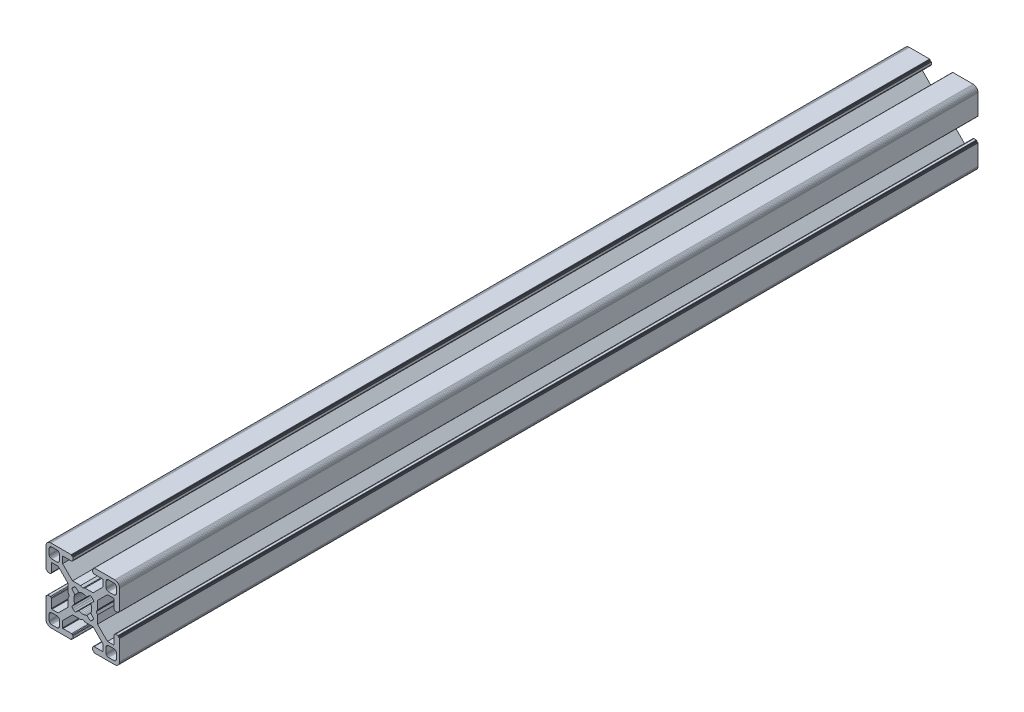
from build123d import *

# Parameters (mm, degrees)
BOSS_EXTRUDE1_DEPTH = 350


with BuildPart() as part:
    # Sketch1 → Boss-Extrude1 (new body)
    with BuildSketch(Plane.XY):
        Polygon((28.34729664, 29.969613999), (28.000000864, 29.999999329), (19.750000909, 29.999999329), (19.715268165, 29.996961355), (19.681595266, 29.987938702), (19.649999216, 29.973205179), (19.621443003, 29.953207821), (19.596790895, 29.928557575), (19.576793537, 29.899999499), (19.562061876, 29.868405312), (19.55303736, 29.834728688), (19.549999386, 29.799999669), (19.549999386, 29.699999839), (19.546961412, 29.665268958), (19.537936896, 29.631596059), (19.523203373, 29.599998146), (19.503207877, 29.571441934), (19.478557631, 29.546789825), (19.449999556, 29.526794329), (19.418403506, 29.512060806), (19.384728745, 29.503038153), (19.349999726, 29.500000179), (19.249999896, 29.500000179), (19.215267517, 29.496958527), (19.181592755, 29.487935874), (19.149996706, 29.47320235), (19.12143863, 29.453206855), (19.096788384, 29.428554746), (19.076791026, 29.399996671), (19.062057503, 29.368402484), (19.05303485, 29.334725859), (19.049996876, 29.299998703), (19.049996876, 28.39999837), (19.059110798, 28.29580945), (19.08618062, 28.194785165), (19.13038119, 28.099997016), (19.190369539, 28.014324653), (19.264324002, 27.94037019), (19.349996366, 27.88038184), (19.444784515, 27.836181271), (19.545806937, 27.809111449), (19.650010894, 27.799984574), (23.050010706, 27.799984574), (23.084741588, 27.7969466), (23.118414487, 27.787923946), (23.150012399, 27.773190423), (23.178568612, 27.753193065), (23.203220721, 27.728542819), (23.223218079, 27.699984744), (23.237949739, 27.668386831), (23.246974255, 27.634713932), (23.25001142, 27.59998608), (23.25001142, 25.049987618), (19.204474482, 20.999982084), (15.900007876, 20.999982084), (15.000008474, 20.48483404), (14.10000814, 20.999982084), (10.795543398, 20.999982084), (7.997342887, 23.801274731), (6.750011387, 25.049984589), (6.750011387, 27.599983051), (6.753049362, 27.634713932), (6.762072946, 27.668386831), (6.776805538, 27.699984744), (6.796801965, 27.728542819), (6.821454073, 27.753193065), (6.850011218, 27.773190423), (6.881607267, 27.787923946), (6.915282029, 27.7969466), (6.950011048, 27.799984574), (10.350011791, 27.799984574), (10.45420071, 27.809098497), (10.555223133, 27.836168318), (10.650011282, 27.880368888), (10.735683645, 27.940357238), (10.809638108, 28.014311701), (10.869626458, 28.099984064), (10.913827027, 28.194772213), (10.940895918, 28.295796498), (10.950010772, 28.399985417), (10.950010772, 29.299985751), (10.946974575, 29.334739239), (10.93795065, 29.368415522), (10.923215933, 29.400009153), (10.903218427, 29.428566473), (10.878566319, 29.45321765), (10.849999264, 29.473204166), (10.818403214, 29.487937689), (10.784728453, 29.496960342), (10.749999434, 29.500000179), (10.649999604, 29.500000179), (10.615270585, 29.503038153), (10.581595823, 29.512060806), (10.549999774, 29.526794329), (10.521441698, 29.546789825), (10.496791452, 29.571441934), (10.476795025, 29.599998146), (10.462061502, 29.631596059), (10.453037918, 29.665268958), (10.449999943, 29.699999839), (10.449999943, 29.799999669), (10.446961969, 29.834728688), (10.437938385, 29.868405312), (10.423205793, 29.899999499), (10.403208435, 29.928557575), (10.378557257, 29.953207821), (10.350000113, 29.973205179), (10.318404064, 29.987938702), (10.284729302, 29.996961355), (10.250000283, 29.999999329), (1.999999397, 29.999999329), (1.652702689, 29.969613999), (1.315958682, 29.879383743), (0.999999233, 29.732050374), (0.714424066, 29.532089829), (0.467910431, 29.285576195), (0.267948955, 28.999999166), (0.120614655, 28.684040532), (0.030384399, 28.34729664), (0, 28.000000864), (0, 19.750000909), (0.003037974, 19.715268165), (0.012061559, 19.681595266), (0.026795082, 19.649999216), (0.046790577, 19.621441141), (0.071442686, 19.596789032), (0.09999983, 19.576793537), (0.13159588, 19.562060013), (0.165270641, 19.55303736), (0.19999966, 19.549999386), (0.299999461, 19.549999386), (0.334728509, 19.546959549), (0.368403242, 19.537936896), (0.399999321, 19.523203373), (0.428556465, 19.503207877), (0.453208573, 19.478555769), (0.473204069, 19.449997693), (0.487937592, 19.418403506), (0.496961176, 19.384728745), (0.499999151, 19.349999726), (0.499999151, 19.249998033), (0.503038056, 19.215269014), (0.512060709, 19.181594253), (0.526794232, 19.150000066), (0.546790194, 19.121441524), (0.571441837, 19.096789882), (0.60000029, 19.076794925), (0.631595686, 19.062061999), (0.665270619, 19.053039982), (0.700000626, 19.050000801), (1.60000096, 19.050000801), (1.704189879, 19.059116587), (1.805213233, 19.086186409), (1.90000045, 19.130385115), (1.985673745, 19.190375328), (2.059627277, 19.264327928), (2.119616325, 19.350002154), (2.163816196, 19.444788441), (2.190886018, 19.545812726), (2.200000872, 19.650001645), (2.200000872, 23.050001457), (2.203039777, 23.084732338), (2.212062431, 23.118405237), (2.226795954, 23.15000315), (2.246792381, 23.178559362), (2.271443558, 23.203211471), (2.300000702, 23.223206967), (2.331596752, 23.23794049), (2.365271513, 23.246965006), (2.400001464, 23.250001117), (4.950000857, 23.250001117), (7.997332093, 20.202670812), (8.995535423, 19.204467788), (8.995535423, 15.900001182), (9.515148227, 15.00000178), (8.995535423, 14.100002378), (8.995535423, 10.795536704), (4.950000857, 6.750002138), (2.400001464, 6.750002138), (2.365271513, 6.753040112), (2.331596752, 6.762063697), (2.300000702, 6.77679722), (2.271443558, 6.796793647), (2.246792381, 6.821444824), (2.226795954, 6.850001968), (2.212062431, 6.881598018), (2.203039777, 6.915272779), (2.200000872, 6.950002729), (2.200000872, 10.350002542), (2.190896812, 10.454174265), (2.16382699, 10.555197618), (2.119627119, 10.649984836), (2.059638071, 10.735658131), (1.985684539, 10.809611663), (1.900011244, 10.869600944), (1.805224027, 10.913800582), (1.704200673, 10.940870404), (1.600011754, 10.949986189), (0.70001142, 10.949986189), (0.665281355, 10.946948596), (0.631606253, 10.937926283), (0.600010578, 10.923193954), (0.571451747, 10.903199537), (0.546799638, 10.87854836), (0.526794232, 10.850000195), (0.512060709, 10.818404146), (0.503038056, 10.784730315), (0.499999151, 10.750000365), (0.499999151, 10.650000535), (0.496961176, 10.615270585), (0.487937592, 10.581596754), (0.473204069, 10.550000705), (0.453208573, 10.521443561), (0.428556465, 10.496791452), (0.399999321, 10.476795956), (0.368403242, 10.462062433), (0.334728509, 10.453038849), (0.299999461, 10.449999943), (0.19999966, 10.449999943), (0.165270641, 10.446961969), (0.13159588, 10.437939316), (0.09999983, 10.423205793), (0.071442686, 10.403209366), (0.046790577, 10.378558189), (0.026795082, 10.350000113), (0.012061559, 10.318404064), (0.003037974, 10.284729302), (0, 10.250000283), (0, 1.999999397), (0.030384399, 1.652702689), (0.120614655, 1.315958682), (0.267948955, 0.999999233), (0.467910431, 0.714424066), (0.714424066, 0.467910431), (0.999999233, 0.267948955), (1.315958682, 0.120614655), (1.652702689, 0.030384399), (1.999999397, 0), (10.250000283, 0), (10.284729302, 0.003037974), (10.318404064, 0.012061559), (10.350000113, 0.026795082), (10.378557257, 0.046790577), (10.403208435, 0.071442686), (10.423205793, 0.09999983), (10.437938385, 0.13159588), (10.446961969, 0.165270641), (10.449999943, 0.19999966), (10.449999943, 0.300000422), (10.453037918, 0.334729441), (10.462061502, 0.368404202), (10.476795025, 0.400000252), (10.496791452, 0.428557396), (10.521441698, 0.453208573), (10.549999774, 0.473205), (10.581595823, 0.487938523), (10.615270585, 0.496961176), (10.649999604, 0.500000082), (10.749999434, 0.500000082), (10.784728453, 0.503038056), (10.818403214, 0.512060709), (10.849999264, 0.526794232), (10.878547894, 0.546800104), (10.903198606, 0.571451747), (10.923194493, 0.6000102), (10.93792742, 0.631606528), (10.946949437, 0.66528146), (10.950010772, 0.699984975), (10.950010772, 1.599985308), (10.940895918, 1.704174228), (10.913827027, 1.805197581), (10.869626458, 1.89998573), (10.809638108, 1.985658094), (10.735683645, 2.059612557), (10.650011282, 2.119600674), (10.555223133, 2.163801476), (10.45420071, 2.190870367), (10.350011791, 2.199985221), (6.950011048, 2.199985221), (6.915282029, 2.203024126), (6.881607267, 2.212046779), (6.850011218, 2.226780302), (6.821454073, 2.246776729), (6.796801965, 2.271427907), (6.776805538, 2.299985982), (6.762072946, 2.331582032), (6.753049362, 2.365256793), (6.750011387, 2.399985812), (6.750011387, 4.949985206), (9.787457566, 7.990785077), (10.795545277, 8.999985833), (14.100010019, 8.999985833), (15.000010353, 9.515133877), (15.900009756, 8.999985833), (19.204476361, 8.999985833), (20.21256413, 7.990786065), (23.25001142, 4.949988235), (23.25001142, 2.399988841), (23.246974255, 2.365256793), (23.237949739, 2.331582032), (23.223218079, 2.299985982), (23.203220721, 2.271427907), (23.178568612, 2.246776729), (23.150012399, 2.226780302), (23.118414487, 2.212046779), (23.084741588, 2.203024126), (23.050010706, 2.199985221), (19.650010894, 2.199985221), (19.545806937, 2.190883319), (19.444784515, 2.163814428), (19.349996366, 2.119613626), (19.264324002, 2.059625509), (19.190369539, 1.985671046), (19.13038119, 1.899998682), (19.08618062, 1.805210533), (19.059110798, 1.70418718), (19.049996876, 1.599998261), (19.049996876, 0.699997927), (19.053035506, 0.665268966), (19.062058795, 0.631594374), (19.076792915, 0.599998603), (19.096790813, 0.571440905), (19.121441524, 0.546790194), (19.149999978, 0.526794306), (19.181596306, 0.51206138), (19.215271238, 0.503039363), (19.249999896, 0.500000082), (19.349999726, 0.500000082), (19.384728745, 0.496961176), (19.418403506, 0.487938523), (19.449999556, 0.473205), (19.478557631, 0.453208573), (19.503207877, 0.428557396), (19.523203373, 0.400000252), (19.537936896, 0.368404202), (19.546961412, 0.334729441), (19.549999386, 0.300000422), (19.549999386, 0.19999966), (19.55303736, 0.165270641), (19.562061876, 0.13159588), (19.576793537, 0.09999983), (19.596789964, 0.071441755), (19.621442072, 0.046789646), (19.649998285, 0.02679415), (19.681594335, 0.012060627), (19.715267234, 0.003037043), (19.750000909, 0), (28.000000864, 0), (28.34729664, 0.030384399), (28.684040532, 0.120614655), (28.999999166, 0.267948955), (29.285576195, 0.467910431), (29.532089829, 0.714424066), (29.732050374, 0.999999233), (29.879383743, 1.315958682), (29.969613999, 1.652702689), (29.999999329, 1.999999397), (29.999999329, 10.250000283), (29.996974806, 10.284715361), (29.987951516, 10.318389952), (29.973217396, 10.349985723), (29.953219499, 10.378543421), (29.928568787, 10.403194133), (29.899999499, 10.423205793), (29.868405312, 10.437939316), (29.834728688, 10.446961969), (29.799999669, 10.449999943), (29.699999839, 10.449999943), (29.664909937, 10.453400043), (29.631233313, 10.462423628), (29.599637263, 10.477157151), (29.57108105, 10.497152646), (29.546427079, 10.521804755), (29.526433446, 10.550361899), (29.511699923, 10.581957949), (29.502675407, 10.615631779), (29.499637433, 10.650361729), (29.499637433, 10.750361559), (29.49697202, 10.784715548), (29.487949367, 10.818389378), (29.473215844, 10.849985428), (29.453220348, 10.878542572), (29.428568239, 10.90319468), (29.400010164, 10.923190176), (29.368415977, 10.937923699), (29.334741215, 10.946947284), (29.300012197, 10.949986189), (28.400011863, 10.949986189), (28.29581215, 10.9408876), (28.194787865, 10.913817778), (28.099999716, 10.86961814), (28.014327352, 10.809628859), (27.940374752, 10.735675327), (27.880384539, 10.650002032), (27.836185833, 10.555214814), (27.809114148, 10.454191461), (27.800000225, 10.350002542), (27.800000225, 6.950002729), (27.796962251, 6.915272779), (27.787939598, 6.881598018), (27.773206075, 6.850001968), (27.753208716, 6.821444824), (27.728558471, 6.796793647), (27.700000395, 6.77679722), (27.668404345, 6.762063697), (27.634729584, 6.753040112), (27.599998702, 6.750002138), (25.05000024, 6.750002138), (23.809199132, 7.99080223), (21.004464477, 10.795534588), (21.004464477, 14.100000262), (20.484851673, 14.999999665), (21.004464477, 15.899999067), (21.004464477, 19.204465672), (25.05000024, 23.250001117), (27.599998702, 23.250001117), (27.634729584, 23.246965006), (27.668404345, 23.23794049), (27.700000395, 23.223206967), (27.728558471, 23.203211471), (27.753208716, 23.178559362), (27.773206075, 23.15000315), (27.787939598, 23.118405237), (27.796962251, 23.084732338), (27.800000225, 23.050001457), (27.800000225, 19.650001645), (27.809114148, 19.545812726), (27.836185833, 19.444788441), (27.880384539, 19.350002154), (27.940370508, 19.264323684), (28.014323108, 19.190371084), (28.099995472, 19.130380872), (28.194783621, 19.086182165), (28.295807906, 19.059112343), (28.400001069, 19.050000801), (29.300001402, 19.050000801), (29.334730421, 19.053040638), (29.368405183, 19.062063291), (29.39999937, 19.076796814), (29.42819671, 19.097149726), (29.452848353, 19.1218023), (29.472843309, 19.150360754), (29.487576235, 19.181955219), (29.496598252, 19.215630151), (29.499637433, 19.250359227), (29.499637433, 19.35036092), (29.502675407, 19.385089939), (29.511699923, 19.4187647), (29.526433446, 19.450358887), (29.546427079, 19.478916963), (29.57108105, 19.503569071), (29.599637263, 19.523564567), (29.631233313, 19.53829809), (29.664909937, 19.547320743), (29.699999839, 19.549999386), (29.799999669, 19.549999386), (29.834728688, 19.55303736), (29.868405312, 19.562060013), (29.899999499, 19.576793537), (29.928557575, 19.596789032), (29.953207821, 19.621441141), (29.973205179, 19.649999216), (29.987938702, 19.681595266), (29.996961355, 19.715268165), (29.999999329, 19.750000909), (29.999999329, 28.000000864), (29.969613999, 28.34729664), (29.879383743, 28.684040532), (29.732050374, 28.999999166), (29.532089829, 29.285576195), (29.285576195, 29.532089829), (28.999999166, 29.732050374), (28.684040532, 29.879383743), align=None)
        Polygon((1.299998723, 25.499999523), (1.299998723, 27.699999511), (1.312309876, 27.856435627), (1.348942518, 28.009016067), (1.408992335, 28.153989464), (1.490981318, 28.287785128), (1.592892222, 28.407108039), (1.71221327, 28.50901708), (1.846008119, 28.591006994), (1.9909814, 28.651056811), (2.143563703, 28.687689453), (2.299998887, 28.699999675), (4.499998875, 28.699999675), (4.656434059, 28.687689453), (4.809016362, 28.651056811), (4.953989759, 28.591006994), (5.087784491, 28.50901708), (5.207106471, 28.407108039), (5.309016444, 28.287785128), (5.391005427, 28.153989464), (5.451056175, 28.009016067), (5.487687886, 27.856435627), (5.499999039, 27.699999511), (5.499999039, 25.499999523), (5.487687886, 25.34356527), (5.451056175, 25.190982968), (5.391005427, 25.04600957), (5.309016444, 24.912213907), (5.207106471, 24.792892858), (5.087784491, 24.690981954), (4.953989759, 24.60899204), (4.809016362, 24.548944086), (4.656434059, 24.512309581), (4.499998875, 24.499999359), (2.299998887, 24.499999359), (2.143563703, 24.512309581), (1.9909814, 24.548944086), (1.846008119, 24.60899204), (1.71221327, 24.690981954), (1.592892222, 24.792892858), (1.490981318, 24.912213907), (1.408992335, 25.04600957), (1.348942518, 25.190982968), (1.312309876, 25.34356527), align=None, mode=Mode.SUBTRACT)
        Polygon((25.34356527, 28.687689453), (25.499999523, 28.699999675), (27.699999511, 28.699999675), (27.856435627, 28.687689453), (28.009017929, 28.651056811), (28.153991327, 28.591006994), (28.28778699, 28.50901708), (28.407108039, 28.407108039), (28.50901708, 28.287785128), (28.591006994, 28.153989464), (28.651056811, 28.009016067), (28.687689453, 27.856435627), (28.700001538, 27.699999511), (28.700001538, 25.499999523), (28.687689453, 25.34356527), (28.651056811, 25.190982968), (28.591006994, 25.04600957), (28.50901708, 24.912213907), (28.407108039, 24.792892858), (28.28778699, 24.690981954), (28.153991327, 24.60899204), (28.009017929, 24.548944086), (27.856435627, 24.512309581), (27.699999511, 24.499999359), (25.499999523, 24.499999359), (25.34356527, 24.512309581), (25.190982968, 24.548944086), (25.04600957, 24.60899204), (24.912215769, 24.690981954), (24.792892858, 24.792892858), (24.690981954, 24.912213907), (24.608993903, 25.04600957), (24.548944086, 25.190982968), (24.512311444, 25.34356527), (24.500001222, 25.499999523), (24.500001222, 27.699999511), (24.512311444, 27.856435627), (24.548944086, 28.009016067), (24.608993903, 28.153989464), (24.690981954, 28.287785128), (24.792892858, 28.407108039), (24.912215769, 28.50901708), (25.04600957, 28.591006994), (25.190982968, 28.651056811), align=None, mode=Mode.SUBTRACT)
        Polygon((14.999999665, 18.649999052), (15.550030395, 18.608318642), (16.087498516, 18.484227359), (16.600128263, 18.280562013), (18.13592948, 19.518401474), (18.644984812, 19.11874488), (19.103571773, 18.662061542), (19.505336881, 18.154669553), (18.280562013, 16.600130126), (18.484227359, 16.087498516), (18.608318642, 15.550030395), (18.649999052, 14.999999665), (18.608318642, 14.449968934), (18.484227359, 13.912500814), (18.280562013, 13.399870135), (19.505336881, 11.845329776), (19.103571773, 11.337937787), (18.644984812, 10.881252587), (18.13592948, 10.481598787), (16.600128263, 11.719437316), (16.087498516, 11.515771039), (15.550030395, 11.391680688), (14.999999665, 11.349999346), (14.449968934, 11.391680688), (13.912500814, 11.515771039), (13.399870135, 11.719437316), (11.864069849, 10.481598787), (11.355013587, 10.881252587), (10.896427557, 11.337937787), (10.494662449, 11.845329776), (11.719438247, 13.399870135), (11.515771039, 13.912500814), (11.391680688, 14.449968934), (11.349999346, 14.999999665), (11.391680688, 15.550030395), (11.515771039, 16.087498516), (11.719438247, 16.600130126), (10.494662449, 18.154669553), (10.896427557, 18.662061542), (11.355013587, 19.11874488), (11.864069849, 19.518401474), (13.399870135, 18.280562013), (13.912500814, 18.484227359), (14.449968934, 18.608318642), align=None, mode=Mode.SUBTRACT)
        Polygon((4.499998875, 1.299999771), (2.299998887, 1.299999771), (2.143563703, 1.312310807), (1.9909814, 1.348942518), (1.846008119, 1.408992335), (1.71221327, 1.490982249), (1.592892222, 1.592892222), (1.490981318, 1.712214202), (1.408992335, 1.846008934), (1.348942518, 1.990982331), (1.312309876, 2.143564634), (1.299998723, 2.299998887), (1.299998723, 4.499999806), (1.312309876, 4.656434059), (1.348942518, 4.809017293), (1.408992335, 4.95399069), (1.490981318, 5.087785423), (1.592892222, 5.207106471), (1.71221327, 5.309017375), (1.846008119, 5.391006358), (1.9909814, 5.451056175), (2.143563703, 5.487688817), (2.299998887, 5.49999997), (4.499998875, 5.49999997), (4.656434059, 5.487688817), (4.809016362, 5.451056175), (4.953989759, 5.391006358), (5.087784491, 5.309017375), (5.207106471, 5.207106471), (5.309016444, 5.087785423), (5.391005427, 4.95399069), (5.451056175, 4.809017293), (5.487687886, 4.656434059), (5.499999039, 4.499999806), (5.499999039, 2.299998887), (5.487687886, 2.143564634), (5.451056175, 1.990982331), (5.391005427, 1.846008934), (5.309016444, 1.712214202), (5.207106471, 1.592892222), (5.087784491, 1.490982249), (4.953989759, 1.408992335), (4.809016362, 1.348942518), (4.656434059, 1.312310807), align=None, mode=Mode.SUBTRACT)
        Polygon((27.699999511, 1.299999771), (25.499999523, 1.299999771), (25.34356527, 1.312310807), (25.190982968, 1.348942518), (25.04600957, 1.408992335), (24.912215769, 1.490982249), (24.792892858, 1.592892222), (24.690981954, 1.712214202), (24.608993903, 1.846008934), (24.548944086, 1.990982331), (24.512311444, 2.143564634), (24.500001222, 2.299998887), (24.500001222, 4.499999806), (24.512311444, 4.656434059), (24.548944086, 4.809017293), (24.608993903, 4.95399069), (24.690981954, 5.087785423), (24.792892858, 5.207106471), (24.912215769, 5.309017375), (25.04600957, 5.391006358), (25.190982968, 5.451056175), (25.34356527, 5.487688817), (25.499999523, 5.49999997), (27.699999511, 5.49999997), (27.856435627, 5.487688817), (28.009017929, 5.451056175), (28.153991327, 5.391006358), (28.28778699, 5.309017375), (28.407108039, 5.207106471), (28.50901708, 5.087785423), (28.591006994, 4.95399069), (28.651056811, 4.809017293), (28.687689453, 4.656434059), (28.700001538, 4.499999806), (28.700001538, 2.299998887), (28.687689453, 2.143564634), (28.651056811, 1.990982331), (28.591006994, 1.846008934), (28.50901708, 1.712214202), (28.407108039, 1.592892222), (28.28778699, 1.490982249), (28.153991327, 1.408992335), (28.009017929, 1.348942518), (27.856435627, 1.312310807), align=None, mode=Mode.SUBTRACT)
    extrude(amount=-BOSS_EXTRUDE1_DEPTH)


solid = part.part
